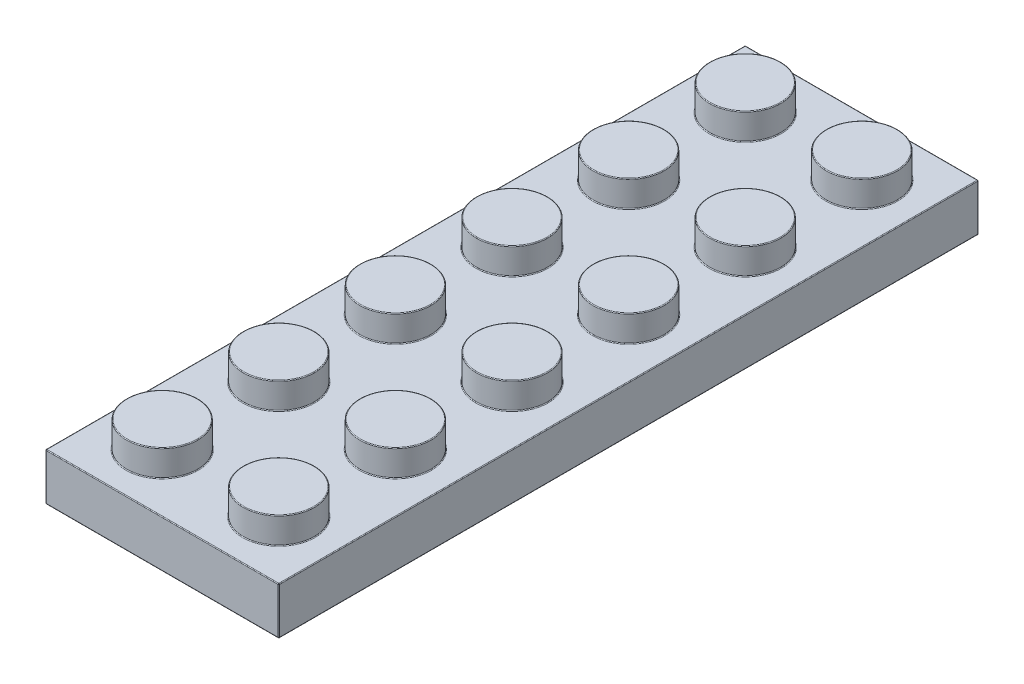
from build123d import *

# Parameters (mm, degrees)
SKETCH1_W                  = 7.96
SKETCH1_H                  = 7.96
EXTRUDE1_DEPTH             = 3.22
SKETCH2_R                  = 2.425
EXTRUDE2_DEPTH             = 1.8
LPATTERN1_COUNT            = 2
LPATTERN1_PITCH            = 7.96
LPATTERN2_COUNT            = 6
LPATTERN2_PITCH            = 7.96
LPATTERN2_COPY_1_SKETCH_W  = 7.96
LPATTERN2_COPY_1_SKETCH_H  = 7.96
LPATTERN2_COPY_1_DEPTH     = 3.22
LPATTERN2_COPY_2_SKETCH_W  = 7.96
LPATTERN2_COPY_2_SKETCH_H  = 7.96
LPATTERN2_COPY_2_DEPTH     = 3.22
LPATTERN2_COPY_3_SKETCH_W  = 7.96
LPATTERN2_COPY_3_SKETCH_H  = 7.96
LPATTERN2_COPY_3_DEPTH     = 3.22
LPATTERN2_COPY_4_SKETCH_W  = 7.96
LPATTERN2_COPY_4_SKETCH_H  = 7.96
LPATTERN2_COPY_4_DEPTH     = 3.22
LPATTERN2_COPY_5_SKETCH_W  = 7.96
LPATTERN2_COPY_5_SKETCH_H  = 7.96
LPATTERN2_COPY_5_DEPTH     = 3.22
LPATTERN2_COPY_6_SKETCH_R  = 2.425
LPATTERN2_COPY_6_DEPTH     = 1.8
LPATTERN2_COPY_7_SKETCH_R  = 2.425
LPATTERN2_COPY_7_DEPTH     = 1.8
LPATTERN2_COPY_8_SKETCH_R  = 2.425
LPATTERN2_COPY_8_DEPTH     = 1.8
LPATTERN2_COPY_9_SKETCH_R  = 2.425
LPATTERN2_COPY_9_DEPTH     = 1.8
LPATTERN2_COPY_10_SKETCH_R = 2.425
LPATTERN2_COPY_10_DEPTH    = 1.8
SHELL1_T                   = -1.55
SKETCH4_W                  = 12.82
SKETCH4_H                  = 44.66
EXTRUDE3_DEPTH             = 0.14
SKETCH5_R                  = 3.23
SKETCH5_R_2                = 2.37
EXTRUDE4_DEPTH             = 1.81
FILLET1_R                  = 0.05


with BuildPart() as part:
    # Sketch1 → Extrude1 (new body)
    with BuildSketch(Plane(origin=(0, 0, 0), x_dir=(1, 0, 0), z_dir=(0, 1, 0))):
        Rectangle(SKETCH1_W, SKETCH1_H)
    extrude1 = extrude(amount=EXTRUDE1_DEPTH)

    # Sketch2 → Extrude2 (add)
    with BuildSketch(Plane(origin=(0, 3.22, 0), x_dir=(1, 0, 0), z_dir=(0, 1, 0))):
        Circle(SKETCH2_R)
    extrude2 = extrude(amount=EXTRUDE2_DEPTH)

    # LPattern1: Extrude1, Extrude2 ×2
    with Locations(*[(i * LPATTERN1_PITCH, 0, 0) for i in range(1, LPATTERN1_COUNT)]):
        add(extrude1)
        add(extrude2)

    # LPattern2: Extrude1, Extrude2 ×6
    with Locations(*[(0, 0, -i * LPATTERN2_PITCH) for i in range(1, LPATTERN2_COUNT)]):
        add(extrude1)
        add(extrude2)

    # LPattern2 copy 1 sketch → LPattern2 copy 1 (add)
    with BuildSketch(Plane(origin=(7.96, 0, -7.96), x_dir=(1, 0, 0), z_dir=(0, 1, 0))):
        Rectangle(LPATTERN2_COPY_1_SKETCH_W, LPATTERN2_COPY_1_SKETCH_H)
    extrude(amount=LPATTERN2_COPY_1_DEPTH)

    # LPattern2 copy 2 sketch → LPattern2 copy 2 (add)
    with BuildSketch(Plane(origin=(7.96, 0, -15.92), x_dir=(1, 0, 0), z_dir=(0, 1, 0))):
        Rectangle(LPATTERN2_COPY_2_SKETCH_W, LPATTERN2_COPY_2_SKETCH_H)
    extrude(amount=LPATTERN2_COPY_2_DEPTH)

    # LPattern2 copy 3 sketch → LPattern2 copy 3 (add)
    with BuildSketch(Plane(origin=(7.96, 0, -23.88), x_dir=(1, 0, 0), z_dir=(0, 1, 0))):
        Rectangle(LPATTERN2_COPY_3_SKETCH_W, LPATTERN2_COPY_3_SKETCH_H)
    extrude(amount=LPATTERN2_COPY_3_DEPTH)

    # LPattern2 copy 4 sketch → LPattern2 copy 4 (add)
    with BuildSketch(Plane(origin=(7.96, 0, -31.84), x_dir=(1, 0, 0), z_dir=(0, 1, 0))):
        Rectangle(LPATTERN2_COPY_4_SKETCH_W, LPATTERN2_COPY_4_SKETCH_H)
    extrude(amount=LPATTERN2_COPY_4_DEPTH)

    # LPattern2 copy 5 sketch → LPattern2 copy 5 (add)
    with BuildSketch(Plane(origin=(7.96, 0, -39.8), x_dir=(1, 0, 0), z_dir=(0, 1, 0))):
        Rectangle(LPATTERN2_COPY_5_SKETCH_W, LPATTERN2_COPY_5_SKETCH_H)
    extrude(amount=LPATTERN2_COPY_5_DEPTH)

    # LPattern2 copy 6 sketch → LPattern2 copy 6 (add)
    with BuildSketch(Plane(origin=(7.96, 3.22, -7.96), x_dir=(1, 0, 0), z_dir=(0, 1, 0))):
        Circle(LPATTERN2_COPY_6_SKETCH_R)
    extrude(amount=LPATTERN2_COPY_6_DEPTH)

    # LPattern2 copy 7 sketch → LPattern2 copy 7 (add)
    with BuildSketch(Plane(origin=(7.96, 3.22, -15.92), x_dir=(1, 0, 0), z_dir=(0, 1, 0))):
        Circle(LPATTERN2_COPY_7_SKETCH_R)
    extrude(amount=LPATTERN2_COPY_7_DEPTH)

    # LPattern2 copy 8 sketch → LPattern2 copy 8 (add)
    with BuildSketch(Plane(origin=(7.96, 3.22, -23.88), x_dir=(1, 0, 0), z_dir=(0, 1, 0))):
        Circle(LPATTERN2_COPY_8_SKETCH_R)
    extrude(amount=LPATTERN2_COPY_8_DEPTH)

    # LPattern2 copy 9 sketch → LPattern2 copy 9 (add)
    with BuildSketch(Plane(origin=(7.96, 3.22, -31.84), x_dir=(1, 0, 0), z_dir=(0, 1, 0))):
        Circle(LPATTERN2_COPY_9_SKETCH_R)
    extrude(amount=LPATTERN2_COPY_9_DEPTH)

    # LPattern2 copy 10 sketch → LPattern2 copy 10 (add)
    with BuildSketch(Plane(origin=(7.96, 3.22, -39.8), x_dir=(1, 0, 0), z_dir=(0, 1, 0))):
        Circle(LPATTERN2_COPY_10_SKETCH_R)
    extrude(amount=LPATTERN2_COPY_10_DEPTH)

    # Shell1
    shell1_openings = [part.faces().sort_by_distance(p)[0] for p in [
        (3.98, 0, -19.9),
    ]]
    offset(amount=SHELL1_T, openings=shell1_openings, kind=Kind.INTERSECTION)

    # Sketch4 → Extrude3 (cut)
    with BuildSketch(Plane.XZ.offset(-1.67)):
        with Locations((3.98, -19.9)):
            Rectangle(SKETCH4_W, SKETCH4_H)
    extrude(amount=-EXTRUDE3_DEPTH, mode=Mode.SUBTRACT)

    # Sketch5 → Extrude4 (add)
    with BuildSketch(Plane.XZ.offset(-1.81)):
        with Locations((3.98, -35.82)):
            Circle(SKETCH5_R)
        with Locations((3.98, -35.82)):
            Circle(SKETCH5_R_2, mode=Mode.SUBTRACT)
        with Locations((3.98, -27.86)):
            Circle(SKETCH5_R)
        with Locations((3.98, -27.86)):
            Circle(SKETCH5_R_2, mode=Mode.SUBTRACT)
        with Locations((3.98, -19.9)):
            Circle(SKETCH5_R)
        with Locations((3.98, -19.9)):
            Circle(SKETCH5_R_2, mode=Mode.SUBTRACT)
        with Locations((3.98, -11.94)):
            Circle(SKETCH5_R)
        with Locations((3.98, -11.94)):
            Circle(SKETCH5_R_2, mode=Mode.SUBTRACT)
        with Locations((3.98, -3.98)):
            Circle(SKETCH5_R)
        with Locations((3.98, -3.98)):
            Circle(SKETCH5_R_2, mode=Mode.SUBTRACT)
    extrude(amount=EXTRUDE4_DEPTH)

    # Fillet1
    fillet1_edges = [part.edges().sort_by_distance(p)[0] for p in [
        (-3.98, 3.22, -19.9),
        (5.535, 3.22, -31.84),
        (5.535, 5.02, -31.84),
        (3.98, 0, -43.78),
        (11.94, 1.61, -43.78),
        (-3.98, 1.61, -43.78),
        (3.98, 3.22, -43.78),
        (-2.425, 3.22, -39.8),
        (-2.425, 5.02, -39.8),
        (5.535, 3.22, -39.8),
        (5.535, 5.02, -39.8),
        (-2.43, 0, -19.9),
        (-2.43, 0.905, -42.23),
        (3.98, 0, 2.43),
        (-2.43, 0.905, 2.43),
        (-0.875, 3.47, 0),
        (10.39, 0, -19.9),
        (10.39, 0.905, 2.43),
        (7.085, 3.47, 0),
        (-0.875, 3.47, -7.96),
        (3.98, 3.22, 3.98),
        (7.085, 3.47, -7.96),
        (-0.875, 3.47, -15.92),
        (7.085, 3.47, -15.92),
        (-0.875, 3.47, -23.88),
        (7.085, 3.47, -23.88),
        (-0.875, 3.47, -31.84),
        (7.085, 3.47, -31.84),
        (3.98, 0, -42.23),
        (10.39, 0.905, -42.23),
        (-0.875, 3.47, -39.8),
        (7.085, 3.47, -39.8),
        (-2.425, 3.22, 0),
        (-2.425, 5.02, 0),
        (-0.875, 1.81, 0),
        (7.085, 1.81, 0),
        (-0.875, 1.81, -7.96),
        (7.085, 1.81, -7.96),
        (-0.875, 1.81, -15.92),
        (7.085, 1.81, -15.92),
        (-0.875, 1.81, -23.88),
        (7.085, 1.81, -23.88),
        (-0.875, 1.81, -31.84),
        (7.085, 1.81, -31.84),
        (-0.875, 1.81, -39.8),
        (7.085, 1.81, -39.8),
        (10.39, 1.81, -19.9),
        (3.98, 1.81, -42.23),
        (-2.43, 1.81, -19.9),
        (3.98, 1.81, 2.43),
        (11.94, 0, -19.9),
        (11.94, 1.61, 3.98),
        (11.94, 3.22, -19.9),
        (0.75, 1.81, -35.82),
        (1.61, 1.81, -35.82),
        (0.75, 0, -35.82),
        (1.61, 0, -35.82),
        (0.75, 1.81, -27.86),
        (1.61, 1.81, -27.86),
        (0.75, 0, -27.86),
        (1.61, 0, -27.86),
        (0.75, 1.81, -19.9),
        (1.61, 1.81, -19.9),
        (0.75, 0, -19.9),
        (1.61, 0, -19.9),
        (0.75, 1.81, -11.94),
        (1.61, 1.81, -11.94),
        (0.75, 0, -11.94),
        (1.61, 0, -11.94),
        (0.75, 1.81, -3.98),
        (1.61, 1.81, -3.98),
        (0.75, 0, -3.98),
        (1.61, 0, -3.98),
        (5.535, 3.22, 0),
        (5.535, 5.02, 0),
        (3.98, 0, 3.98),
        (-2.425, 3.22, -7.96),
        (-2.425, 5.02, -7.96),
        (5.535, 3.22, -7.96),
        (5.535, 5.02, -7.96),
        (-3.98, 0, -19.9),
        (-2.425, 3.22, -15.92),
        (-2.425, 5.02, -15.92),
        (5.535, 3.22, -15.92),
        (5.535, 5.02, -15.92),
        (-3.98, 1.61, 3.98),
        (-2.425, 3.22, -23.88),
        (-2.425, 5.02, -23.88),
        (5.535, 3.22, -23.88),
        (5.535, 5.02, -23.88),
        (-2.425, 3.22, -31.84),
        (-2.425, 5.02, -31.84),
    ]]
    fillet(fillet1_edges, radius=FILLET1_R)


solid = part.part
